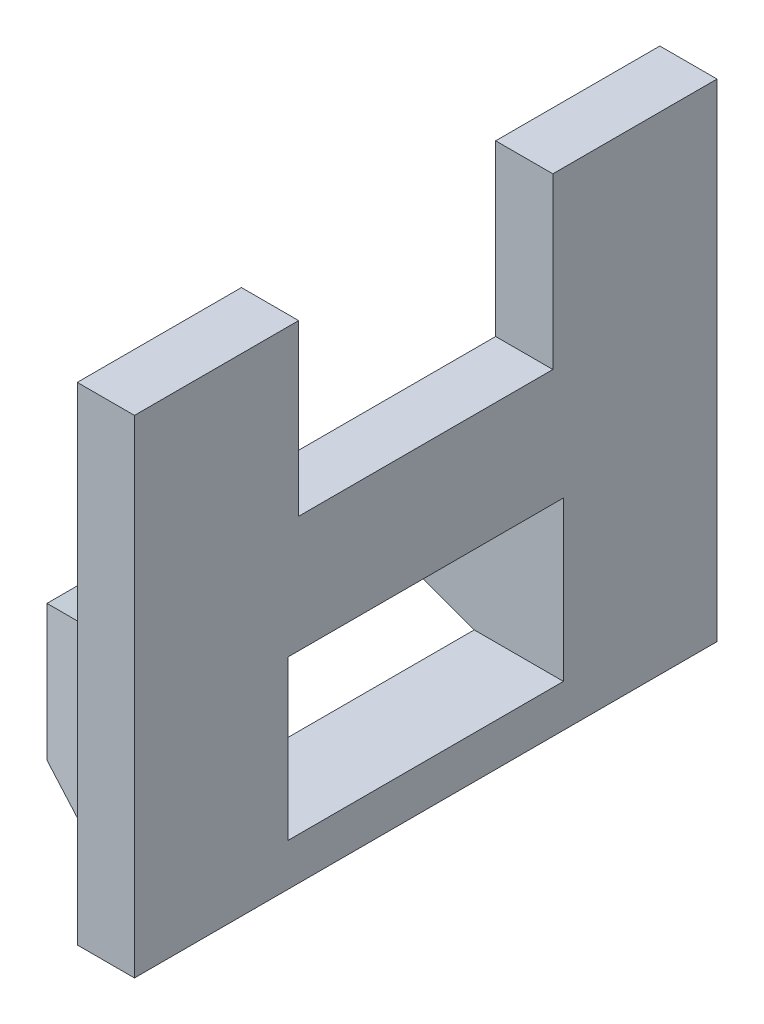
from build123d import *

# Parameters (mm, degrees)
SKETCH1_W           = 27.5
SKETCH1_H           = 23
BOSS_EXTRUDE1_DEPTH = 2.7
SKETCH2_W           = 12
SKETCH2_H           = 8
CUT_EXTRUDE1_DEPTH  = 3.7
SKETCH4_W           = 24
SKETCH4_H           = 10.05
BOSS_EXTRUDE4_DEPTH = 5
BOSS_EXTRUDE4_TAPER = 20
SKETCH3_W           = 13
SKETCH3_H           = 7.5
CUT_EXTRUDE3_DEPTH  = 7.7


with BuildPart() as part:
    # Sketch1 → Boss-Extrude1 (new body)
    with BuildSketch(Plane(origin=(0, 0, 0), x_dir=(0, 0, -1), z_dir=(1, 0, 0))):
        Rectangle(SKETCH1_W, SKETCH1_H)
    extrude(amount=-BOSS_EXTRUDE1_DEPTH)

    # Sketch2 → Cut-Extrude1 (cut, through all)
    with BuildSketch(Plane(origin=(0, 0, 0), x_dir=(0, 0, -1), z_dir=(1, 0, 0))):
        with Locations((0, 7.5)):
            Rectangle(SKETCH2_W, SKETCH2_H)
    extrude(amount=-CUT_EXTRUDE1_DEPTH, mode=Mode.SUBTRACT)

    # Sketch4 → Boss-Extrude4 (add)
    with BuildSketch(Plane.ZY.offset(2.7)):
        with Locations((0, -5.025)):
            Rectangle(SKETCH4_W, SKETCH4_H)
    extrude(amount=BOSS_EXTRUDE4_DEPTH, taper=BOSS_EXTRUDE4_TAPER)

    # Sketch3 → Cut-Extrude3 (cut)
    with BuildSketch(Plane(origin=(0, 0, 0), x_dir=(0, 0, -1), z_dir=(1, 0, 0))):
        with Locations((0, -5.75)):
            Rectangle(SKETCH3_W, SKETCH3_H)
    extrude(amount=-CUT_EXTRUDE3_DEPTH, mode=Mode.SUBTRACT)


solid = part.part
